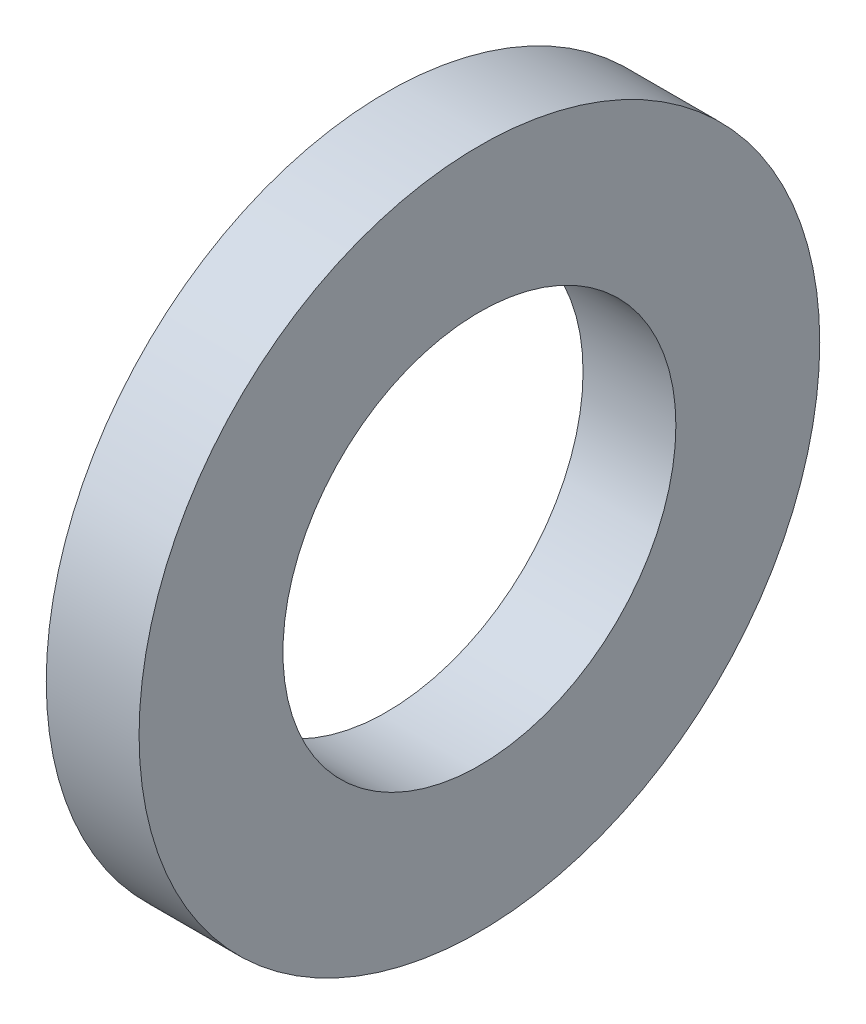
from build123d import *

# Parameters (mm, degrees)
BOSS_EXTRUDE1_DEPTH      = 1.5
BOSS_EXTRUDE1_DEPTH_BACK = 1.5
SKETCH1_R                = 11
SKETCH1_R_2              = 6.35


with BuildPart() as part:
    # Sketch1 → Boss-Extrude1 (new, two sides: drawn at the far end of the back side and taken through both)
    with BuildSketch(Plane(origin=(0, 0, 0), x_dir=(0, 0, -1), z_dir=(1, 0, 0)).offset(-BOSS_EXTRUDE1_DEPTH_BACK)):
        Circle(SKETCH1_R)
        Circle(SKETCH1_R_2, mode=Mode.SUBTRACT)
    extrude(amount=BOSS_EXTRUDE1_DEPTH + BOSS_EXTRUDE1_DEPTH_BACK)


solid = part.part
